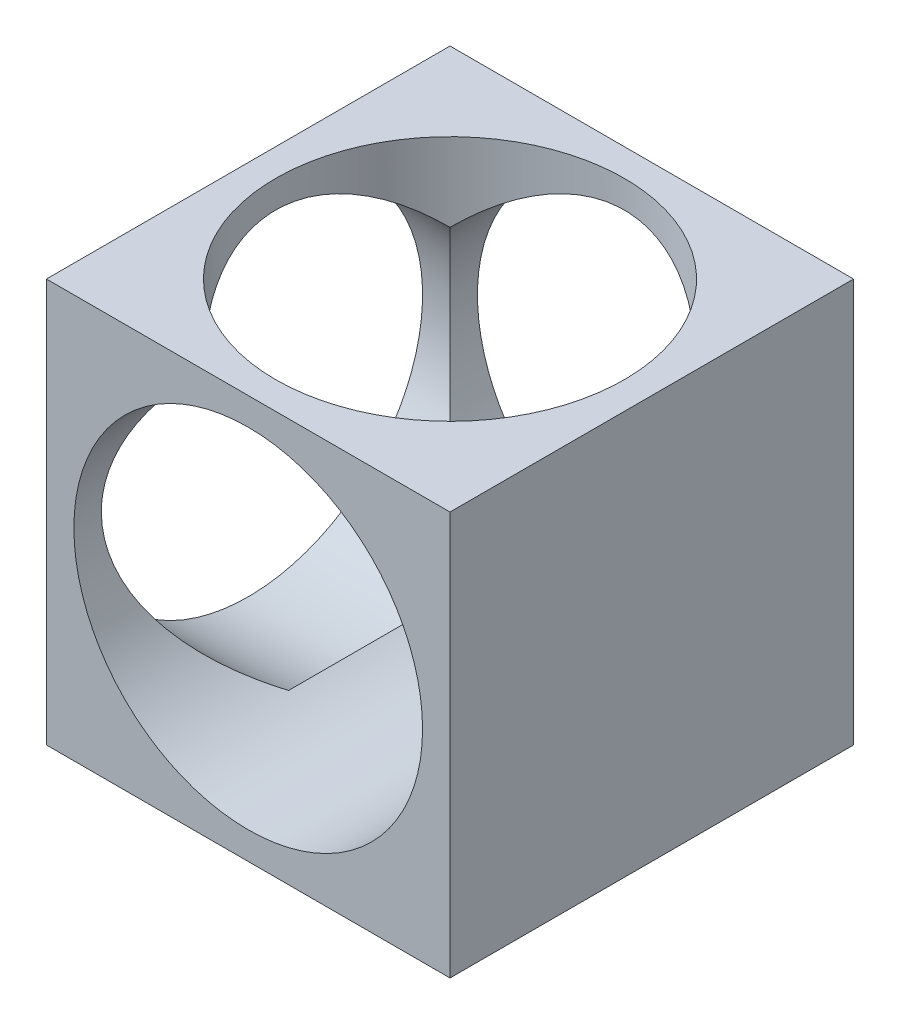
from build123d import *

# Parameters (mm, degrees)
SKETCH2_W               = 31.75
SKETCH2_H               = 31.75
BOSS_EXTRUDE1_DEPTH     = 31.75
SKETCH4_R               = 13.716
CUT_EXTRUDE2_DEPTH      = 1
CUT_EXTRUDE2_DEPTH_BACK = 32.75
SKETCH5_R               = 13.716
CUT_EXTRUDE3_DEPTH      = 9.525
SKETCH3_R               = 13.716
CUT_EXTRUDE4_DEPTH      = 7.62


with BuildPart() as part:
    # Sketch2 → Boss-Extrude1 (new body)
    with BuildSketch(Plane(origin=(0, 0, 0), x_dir=(1, 0, 0), z_dir=(0, 1, 0))):
        Rectangle(SKETCH2_W, SKETCH2_H)
    extrude(amount=BOSS_EXTRUDE1_DEPTH)

    # Sketch4 → Cut-Extrude2 (cut, two sides)
    with BuildSketch(Plane.XY.offset(15.875)) as cut_extrude2_sk:
        with Locations((0, 15.875)):
            Circle(SKETCH4_R)
    extrude(amount=CUT_EXTRUDE2_DEPTH, mode=Mode.SUBTRACT)
    extrude(cut_extrude2_sk.sketch, amount=-CUT_EXTRUDE2_DEPTH_BACK, mode=Mode.SUBTRACT)

    # Sketch5 → Cut-Extrude3 (cut)
    with BuildSketch(Plane.ZY.offset(15.875)):
        with Locations((0, 15.875)):
            Circle(SKETCH5_R)
    extrude(amount=-CUT_EXTRUDE3_DEPTH, mode=Mode.SUBTRACT)

    # Sketch3 → Cut-Extrude4 (cut)
    with BuildSketch(Plane(origin=(0, 31.75, 0), x_dir=(1, 0, 0), z_dir=(0, 1, 0))):
        Circle(SKETCH3_R)
    extrude(amount=-CUT_EXTRUDE4_DEPTH, mode=Mode.SUBTRACT)


solid = part.part
